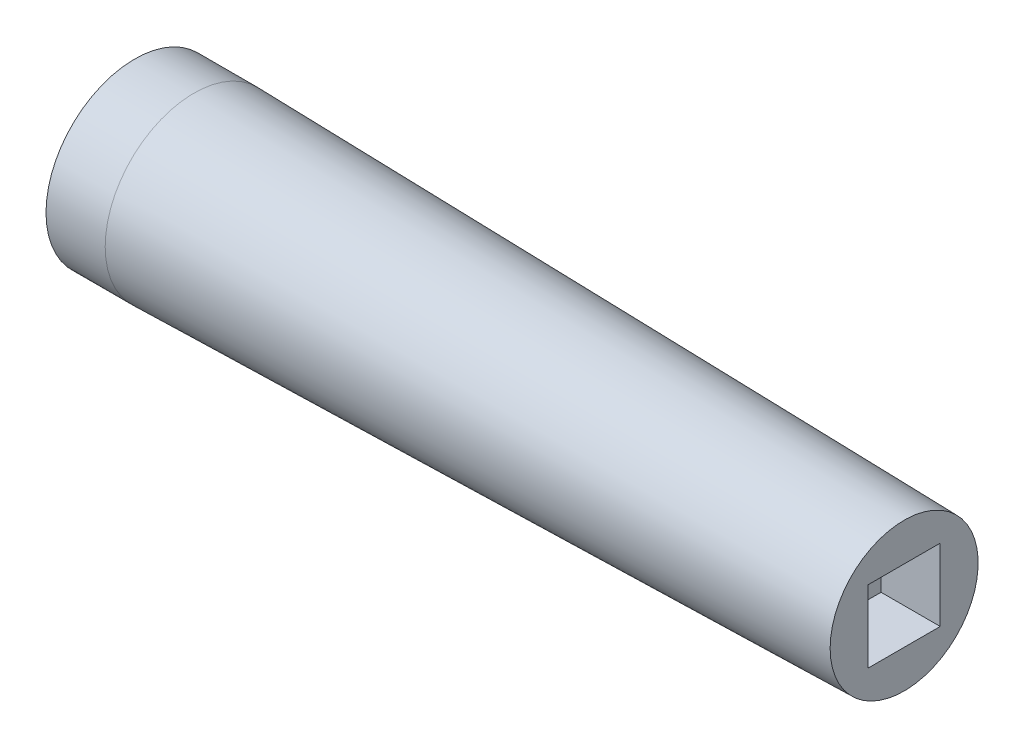
from build123d import *

# Parameters (mm, degrees)
SKETCH2_W          = 15.49
SKETCH2_H          = 15.49
CUT_EXTRUDE1_DEPTH = 12.7


with BuildPart() as part:
    # Sketch1 → Revolve1 (revolve)
    with BuildSketch(Plane(origin=(0, 0, 0), x_dir=(1, 0, 0), z_dir=(0, 1, 0))):
        Polygon((0, 0), (165.1, 0), (165.1, 15.88), (12.7, 19.05), (0, 19.05), align=None)
    revolve(axis=Axis((0, 0, 0), (1, 0, 0)))

    # Sketch2 → Cut-Extrude1 (cut)
    with BuildSketch(Plane(origin=(165.1, 0, 0), x_dir=(0, 0, -1), z_dir=(1, 0, 0))):
        Rectangle(SKETCH2_W, SKETCH2_H)
    extrude(amount=-CUT_EXTRUDE1_DEPTH, mode=Mode.SUBTRACT)


solid = part.part
